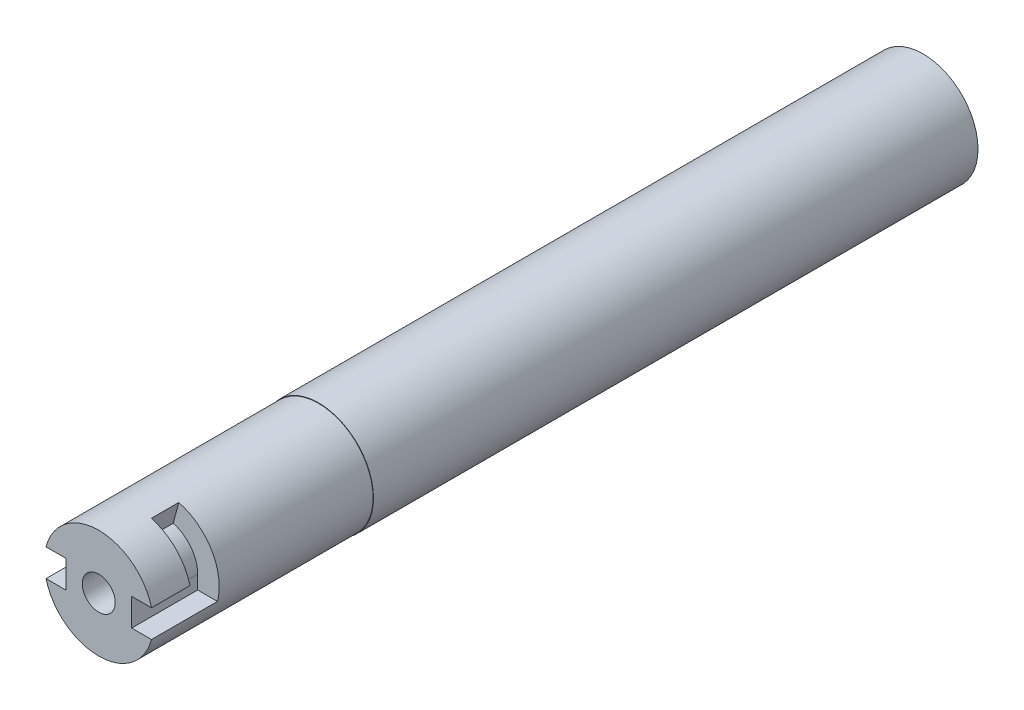
from build123d import *

# Parameters (mm, degrees)
SKETCH1_R           = 6.35
BOSS_EXTRUDE1_DEPTH = 95.25
SKETCH2_R           = 5.08
CUT_EXTRUDE1_DEPTH  = 82.55
SKETCH3_R           = 1.905
CUT_EXTRUDE2_DEPTH  = 114.3
CUT_EXTRUDE8_DEPTH  = 7.62
CUT_REVOLVE1_ANGLE  = 75
SKETCH8_R           = 6.35
SKETCH8_R_2         = 6.2992
CUT_EXTRUDE10_DEPTH = 25.4


with BuildPart() as part:
    # Sketch1 → Boss-Extrude1 (new body)
    with BuildSketch(Plane.XY):
        Circle(SKETCH1_R)
    extrude(amount=BOSS_EXTRUDE1_DEPTH)

    # Sketch2 → Cut-Extrude1 (cut)
    with BuildSketch(Plane(origin=(0, 0, 0), x_dir=(-1, 0, 0), z_dir=(0, 0, -1))):
        Circle(SKETCH2_R)
    extrude(amount=-CUT_EXTRUDE1_DEPTH, mode=Mode.SUBTRACT)

    # Sketch3 → Cut-Extrude2 (cut)
    with BuildSketch(Plane.XY.offset(95.25)):
        Circle(SKETCH3_R)
    extrude(amount=-CUT_EXTRUDE2_DEPTH, mode=Mode.SUBTRACT)

    # Sketch5 → Cut-Extrude8 (cut)
    with BuildSketch(Plane.XY.offset(95.25)):
        with BuildLine():
            ThreePointArc((6.35, 0), (6.299388571, 0.800127257), (6.148361062, 1.5875))
            Line((6.148361062, 1.5875), (3.81, 1.5875))
            Line((3.81, 1.5875), (3.81, -1.5875))
            Line((3.81, -1.5875), (6.148361062, -1.5875))
            ThreePointArc((6.148361062, -1.5875), (6.299388571, -0.800127257), (6.35, 0))
        make_face()
        with BuildLine():
            Line((-3.81, 1.5875), (-6.148361062, 1.5875))
            ThreePointArc((-6.148361062, 1.5875), (-6.35, 0), (-6.148361062, -1.5875))
            Line((-6.148361062, -1.5875), (-3.81, -1.5875))
            Line((-3.81, -1.5875), (-3.81, 1.5875))
        make_face()
    extrude(amount=-CUT_EXTRUDE8_DEPTH, mode=Mode.SUBTRACT)

    # Sketch7 → Cut-Revolve1 (revolve, cut)
    with BuildSketch(Plane(origin=(0, 0, 0), x_dir=(1, 0, 0), z_dir=(0, 1, 0))):
        Polygon((6.148361062, -87.63), (3.81, -87.63), (3.81, -90.805), (6.35, -90.805), (6.35, -87.63), align=None)
        Polygon((-3.81, -90.805), (-6.35, -90.805), (-6.35, -87.63), (-6.148361062, -87.63), (-3.81, -87.63), align=None)
    revolve(axis=Axis((0, 0, 0), (0, 0, 1)), revolution_arc=CUT_REVOLVE1_ANGLE, mode=Mode.SUBTRACT)

    # Sketch8 → Cut-Extrude10 (cut)
    with BuildSketch(Plane.XY.offset(95.25)):
        Circle(SKETCH8_R)
        Circle(SKETCH8_R_2, mode=Mode.SUBTRACT)
    extrude(amount=-CUT_EXTRUDE10_DEPTH, mode=Mode.SUBTRACT)


solid = part.part
